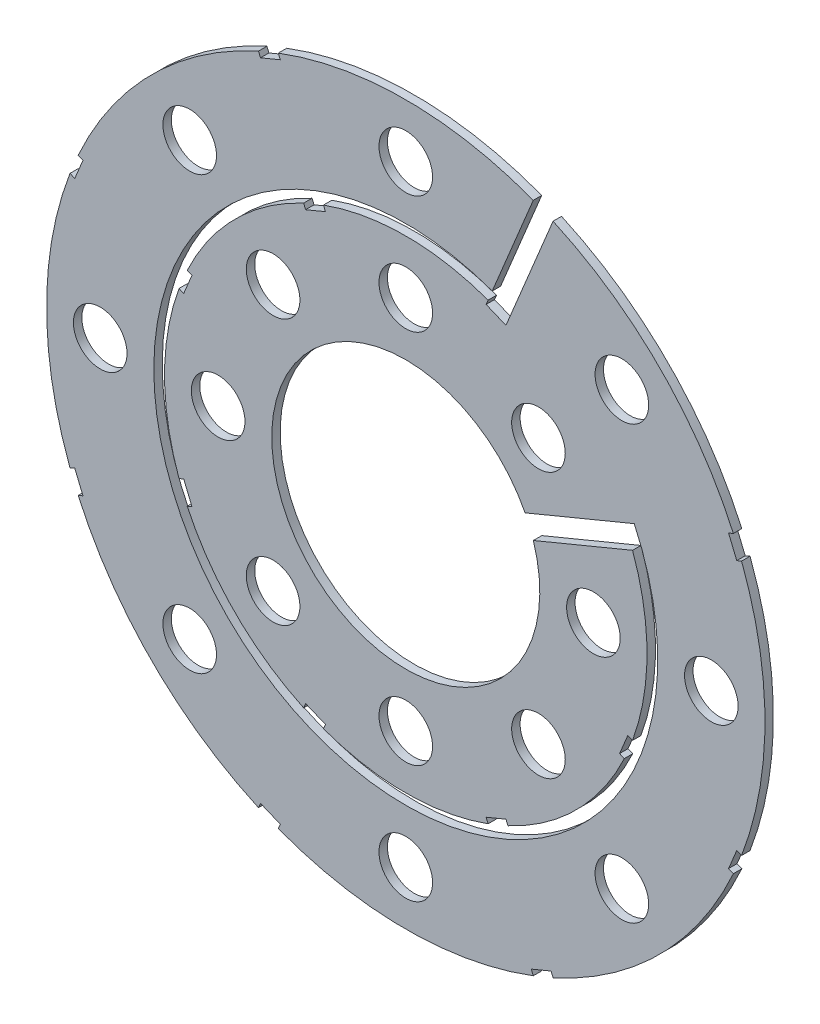
from build123d import *

# Parameters (mm, degrees)
BOSS_EXTRUDE1_DEPTH = 1
SKETCH2_R           = 3.175
CUT_EXTRUDE1_DEPTH  = 2
CUT_EXTRUDE2_DEPTH  = 2


with BuildPart() as part:
    # Sketch1 → Boss-Extrude1 (new body)
    with BuildSketch(Plane.XY):
        with BuildLine():
            Line((10.237514752, 28.034216891), (15.100684157, 39.774946424))
            ThreePointArc((15.100684157, 39.774946424), (-16.28126663, -39.306454711), (17.447338169, 38.802930505))
            Line((17.447338169, 38.802930505), (12.097700571, 25.88776286))
            ThreePointArc((12.097700571, 25.88776286), (-21.083635895, -19.287584671), (26.859778778, 9.751046558))
            Line((26.859778778, 9.751046558), (15.105587123, 4.88230096))
            ThreePointArc((15.105587123, 4.88230096), (-14.666587579, -6.075099489), (14.133571205, 7.228954972))
            Line((14.133571205, 7.228954972), (27.062200973, 12.584168765))
            ThreePointArc((27.062200973, 12.584168765), (-20.186460687, -21.982511911), (10.237514752, 28.034216891))
        make_face()
    extrude(amount=BOSS_EXTRUDE1_DEPTH)

    # Sketch2 → Cut-Extrude1 (cut, through all)
    with BuildSketch(Plane.XY.offset(1)):
        with Locations((22.225, 1.106e-06)):
            Circle(SKETCH2_R)
        with Locations((36.195, 0)):
            Circle(SKETCH2_R)
        with Locations((15.715448994, -15.71544743)):
            Circle(SKETCH2_R)
        with Locations((25.593729945, -25.593729945)):
            Circle(SKETCH2_R)
        with Locations((1.106e-06, -22.225)):
            Circle(SKETCH2_R)
        with Locations((0, -36.195)):
            Circle(SKETCH2_R)
        with Locations((-15.71544743, -15.715448994)):
            Circle(SKETCH2_R)
        with Locations((-25.593729945, -25.593729945)):
            Circle(SKETCH2_R)
        with Locations((-22.225, -1.106e-06)):
            Circle(SKETCH2_R)
        with Locations((-36.195, 0)):
            Circle(SKETCH2_R)
        with Locations((-15.715448994, 15.71544743)):
            Circle(SKETCH2_R)
        with Locations((-25.593729945, 25.593729945)):
            Circle(SKETCH2_R)
        with Locations((-1.106e-06, 22.225)):
            Circle(SKETCH2_R)
        with Locations((0, 36.195)):
            Circle(SKETCH2_R)
        with Locations((15.71544743, 15.715448994)):
            Circle(SKETCH2_R)
        with Locations((25.593729945, 25.593729945)):
            Circle(SKETCH2_R)
    extrude(amount=-CUT_EXTRUDE1_DEPTH, mode=Mode.SUBTRACT)

    # Sketch3 → Cut-Extrude2 (cut, through all)
    with BuildSketch(Plane.XY.offset(1)):
        Polygon((25.327186179, -11.865502107), (26.500513186, -12.351510066), (27.472529104, -10.004856053), (26.299202097, -9.518848094), align=None)
        Polygon((10.004856053, -27.472529104), (12.351510066, -26.500513186), (11.865502107, -25.327186179), (9.518848094, -26.299202097), align=None)
        Polygon((-12.351510066, -26.500513186), (-10.004856053, -27.472529104), (-9.518848094, -26.299202097), (-11.865502107, -25.327186179), align=None)
        Polygon((-27.472529104, -10.004856053), (-26.500513186, -12.351510066), (-25.327186179, -11.865502107), (-26.299202097, -9.518848094), align=None)
        Polygon((-26.500513186, 12.351510066), (-27.472529104, 10.004856053), (-26.299202097, 9.518848094), (-25.327186179, 11.865502107), align=None)
        Polygon((-10.004856053, 27.472529104), (-12.351510066, 26.500513186), (-11.865502107, 25.327186179), (-9.518848094, 26.299202097), align=None)
        Polygon((12.351510066, 26.500513186), (10.004856053, 27.472529104), (9.518848094, 26.299202097), (11.865502107, 25.327186179), align=None)
        Polygon((39.205799167, 14.864935644), (40.379126173, 15.350943603), (39.407110255, 17.697597616), (38.233783248, 17.211589657), align=None)
        Polygon((39.205799167, -14.864935644), (40.379126173, -15.350943603), (39.407110255, -17.697597616), (38.233783248, -17.211589657), align=None)
        Polygon((17.211589657, -38.233783248), (17.697597616, -39.407110255), (15.350943603, -40.379126173), (14.864935644, -39.205799167), align=None)
        Polygon((-14.864935644, -39.205799167), (-15.350943603, -40.379126173), (-17.697597616, -39.407110255), (-17.211589657, -38.233783248), align=None)
        Polygon((-38.233783248, -17.211589657), (-39.407110255, -17.697597616), (-40.379126173, -15.350943603), (-39.205799167, -14.864935644), align=None)
        Polygon((-39.205799167, 14.864935644), (-40.379126173, 15.350943603), (-39.407110255, 17.697597616), (-38.233783248, 17.211589657), align=None)
        Polygon((-17.211589657, 38.233783248), (-17.697597616, 39.407110255), (-15.350943603, 40.379126173), (-14.864935644, 39.205799167), align=None)
    extrude(amount=-CUT_EXTRUDE2_DEPTH, mode=Mode.SUBTRACT)


solid = part.part
